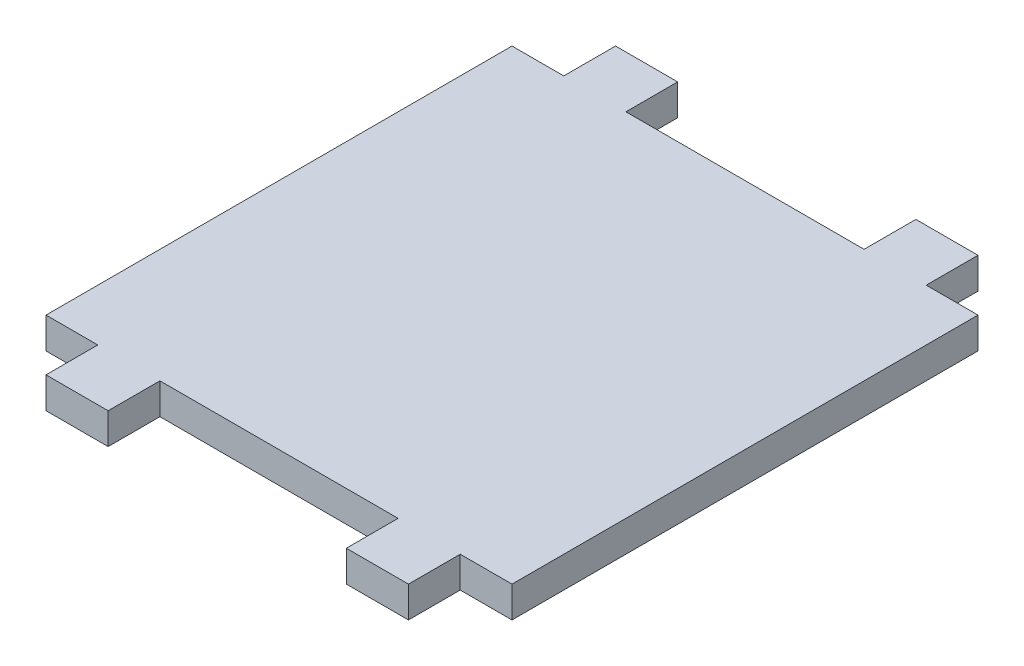
from build123d import *

# Parameters (mm, degrees)
CROQUIS1_W              = 45
CROQUIS1_H              = 45
CROQUIS1_W_2            = 6
CROQUIS1_H_2            = 5
SALIENTE_EXTRUIR1_DEPTH = 3


with BuildPart() as part:
    # Croquis1 → Saliente-Extruir1 (new body)
    with BuildSketch(Plane(origin=(0, 0, 0), x_dir=(1, 0, 0), z_dir=(0, 1, 0))):
        Rectangle(CROQUIS1_W, CROQUIS1_H)
        with Locations((-14.5, 25)):
            Rectangle(CROQUIS1_W_2, CROQUIS1_H_2)
        with Locations((14.5, 25)):
            Rectangle(CROQUIS1_W_2, CROQUIS1_H_2)
        with Locations((14.5, -25)):
            Rectangle(CROQUIS1_W_2, CROQUIS1_H_2)
        with Locations((-14.5, -25)):
            Rectangle(CROQUIS1_W_2, CROQUIS1_H_2)
    extrude(amount=SALIENTE_EXTRUIR1_DEPTH)


solid = part.part
